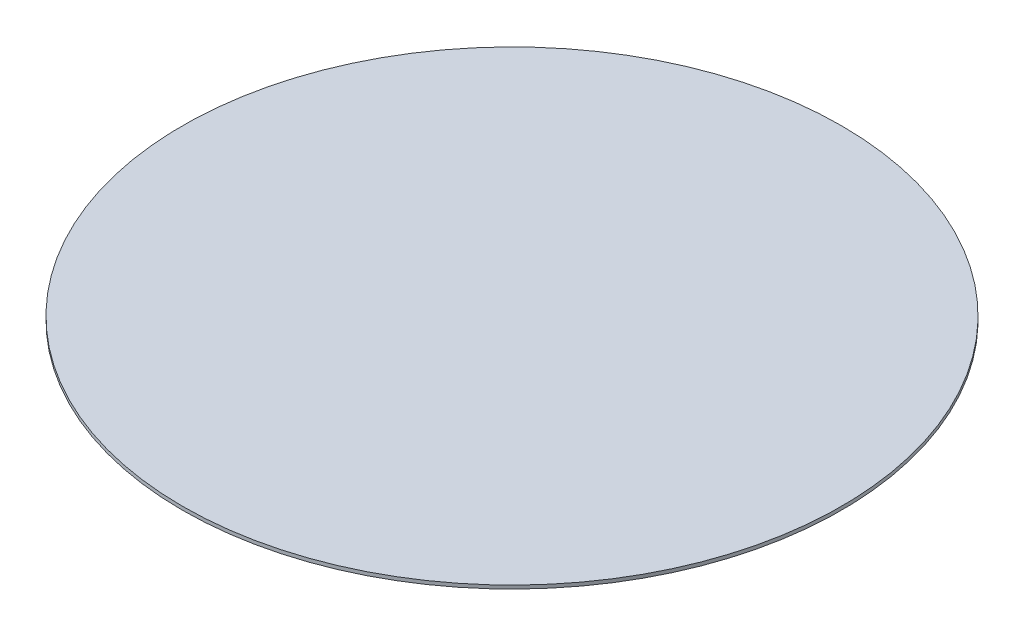
from build123d import *

# Parameters (mm, degrees)
SCHIZZO1_R                   = 9.5
ESTRUSIONE_ESTRUSIONE1_DEPTH = 0.1


with BuildPart() as part:
    # Schizzo1 → Estrusione-Estrusione1 (new body)
    with BuildSketch(Plane(origin=(0, 0, 0), x_dir=(1, 0, 0), z_dir=(0, 1, 0))):
        Circle(SCHIZZO1_R)
    extrude(amount=ESTRUSIONE_ESTRUSIONE1_DEPTH)


solid = part.part
